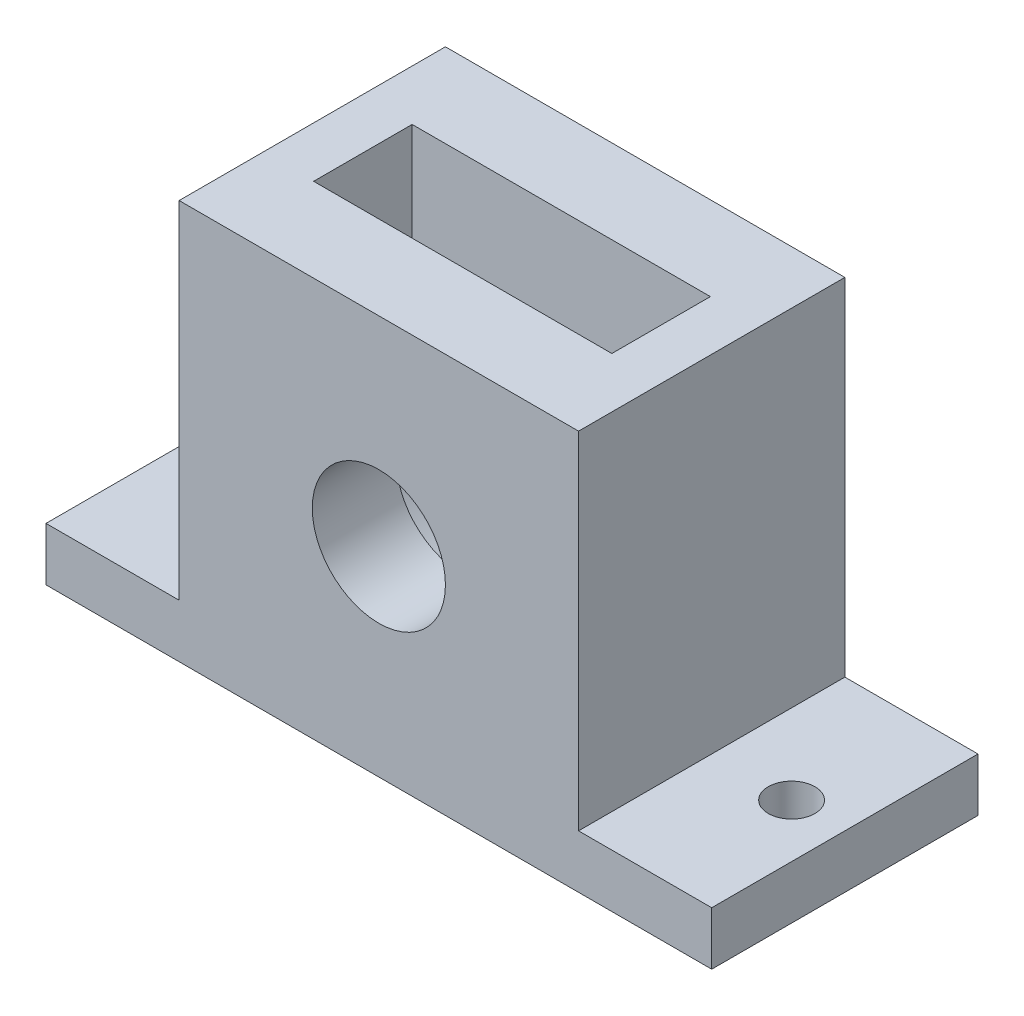
from build123d import *

# Parameters (mm, degrees)
SKETCH2_W           = 30
SKETCH2_H           = 30
SKETCH2_R           = 5
BOSS_EXTRUDE1_DEPTH = 20
CUT_EXTRUDE2_START  = 10
CUT_EXTRUDE2_DEPTH  = 3.7
SKETCH4_W           = 10
SKETCH4_H           = 20
SKETCH4_R           = 1.75
BOSS_EXTRUDE2_DEPTH = 4


with BuildPart() as part:
    # Sketch2 → Boss-Extrude1 (new body)
    with BuildSketch(Plane.XY):
        Rectangle(SKETCH2_W, SKETCH2_H)
        Circle(SKETCH2_R, mode=Mode.SUBTRACT)
    extrude(amount=BOSS_EXTRUDE1_DEPTH)

    # Sketch3 → Cut-Extrude2 (cut, symmetric)
    with BuildSketch(Plane.XY.offset(CUT_EXTRUDE2_START)):
        with BuildLine():
            Line((-11.2, 15), (-11.2, 0))
            ThreePointArc((-11.2, 0), (0, -11.2), (11.2, 0))
            Line((11.2, 0), (11.2, 15))
            Line((11.2, 15), (-11.2, 15))
        make_face()
    extrude(amount=CUT_EXTRUDE2_DEPTH, both=True, mode=Mode.SUBTRACT)

    # Sketch4 → Boss-Extrude2 (add)
    with BuildSketch(Plane.XZ.offset(15)):
        with Locations((-20, 10)):
            Rectangle(SKETCH4_W, SKETCH4_H)
        with Locations((-21, 10)):
            Circle(SKETCH4_R, mode=Mode.SUBTRACT)
        with Locations((20, 10)):
            Rectangle(SKETCH4_W, SKETCH4_H)
        with Locations((21, 10)):
            Circle(SKETCH4_R, mode=Mode.SUBTRACT)
    extrude(amount=-BOSS_EXTRUDE2_DEPTH)


solid = part.part
